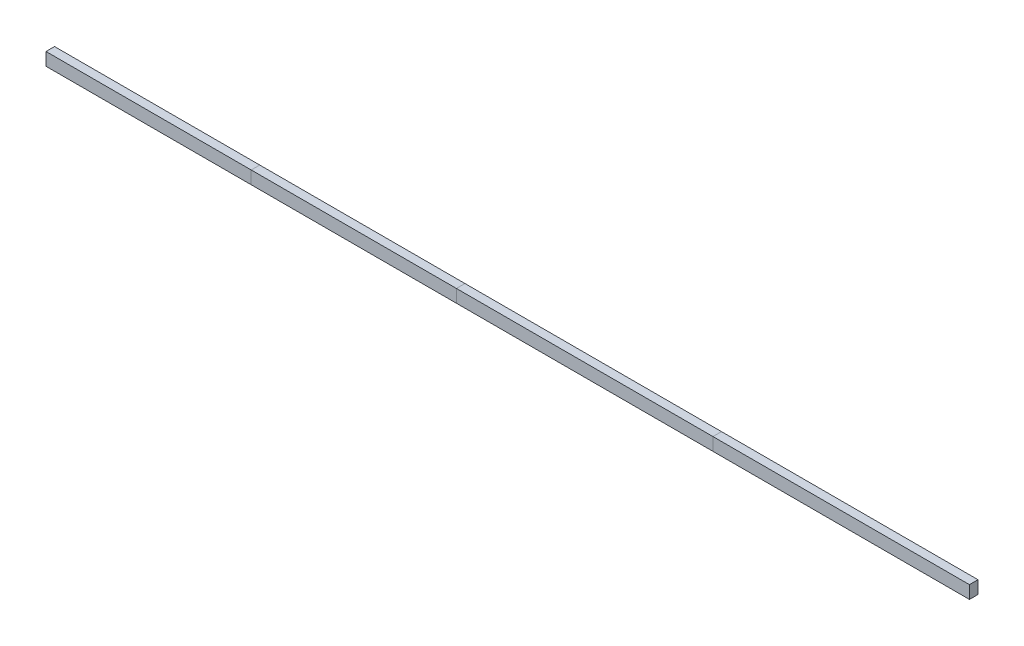
from build123d import *

# Parameters (mm, degrees)
SKETCH2_W           = 50.8
SKETCH2_H           = 76.2
BOSS_EXTRUDE1_DEPTH = 1219.2
BOSS_EXTRUDE5_START = 1219.2
SKETCH2_8_W         = 50.8
SKETCH2_8_H         = 76.2
BOSS_EXTRUDE5_DEPTH = 1219.2
BOSS_EXTRUDE6_START = 2438.4
SKETCH2_9_W         = 50.8
SKETCH2_9_H         = 76.2
BOSS_EXTRUDE6_DEPTH = 1524
BOSS_EXTRUDE7_START = 3962.4
SKETCH2_10_W        = 50.8
SKETCH2_10_H        = 76.2
BOSS_EXTRUDE7_DEPTH = 1524


with BuildPart() as part:
    # Sketch2 → Boss-Extrude1 (new body)
    with BuildSketch(Plane(origin=(0, 0, 0), x_dir=(0, 0, -1), z_dir=(1, 0, 0))):
        Rectangle(SKETCH2_W, SKETCH2_H)
    extrude(amount=BOSS_EXTRUDE1_DEPTH)


with BuildPart() as body_2:
    # Sketch2_8 → Boss-Extrude5 (new body)
    with BuildSketch(Plane(origin=(0, 0, 0), x_dir=(0, 0, -1), z_dir=(1, 0, 0)).offset(BOSS_EXTRUDE5_START)):
        Rectangle(SKETCH2_8_W, SKETCH2_8_H)
    extrude(amount=BOSS_EXTRUDE5_DEPTH)


with BuildPart() as body_3:
    # Sketch2_9 → Boss-Extrude6 (new body)
    with BuildSketch(Plane(origin=(0, 0, 0), x_dir=(0, 0, -1), z_dir=(1, 0, 0)).offset(BOSS_EXTRUDE6_START)):
        Rectangle(SKETCH2_9_W, SKETCH2_9_H)
    extrude(amount=BOSS_EXTRUDE6_DEPTH)


with BuildPart() as body_4:
    # Sketch2_10 → Boss-Extrude7 (new body)
    with BuildSketch(Plane(origin=(0, 0, 0), x_dir=(0, 0, -1), z_dir=(1, 0, 0)).offset(BOSS_EXTRUDE7_START)):
        Rectangle(SKETCH2_10_W, SKETCH2_10_H)
    extrude(amount=BOSS_EXTRUDE7_DEPTH)


solid = Compound([part.part, body_2.part, body_3.part, body_4.part])
